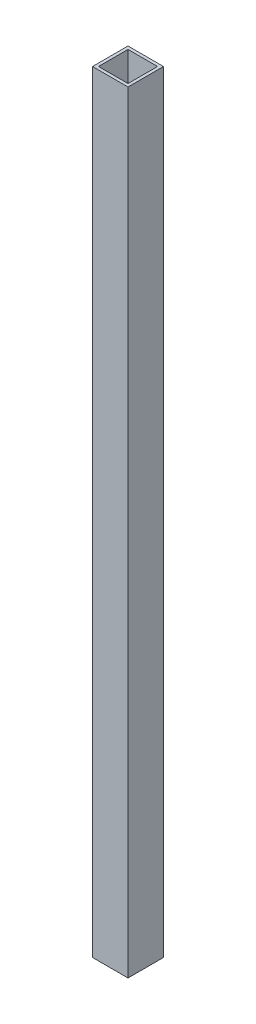
from build123d import *

# Parameters (mm, degrees)
SKETCH2_W           = 19.05
SKETCH2_H           = 19.05
SKETCH2_W_2         = 15.875
SKETCH2_H_2         = 15.875
BOSS_EXTRUDE1_DEPTH = 414.3375


with BuildPart() as part:
    # Sketch2 → Boss-Extrude1 (new body)
    with BuildSketch(Plane(origin=(0, 0, 0), x_dir=(1, 0, 0), z_dir=(0, 1, 0))):
        with Locations((9.525, 9.525)):
            Rectangle(SKETCH2_W, SKETCH2_H)
        with Locations((9.525, 9.525)):
            Rectangle(SKETCH2_W_2, SKETCH2_H_2, mode=Mode.SUBTRACT)
    extrude(amount=BOSS_EXTRUDE1_DEPTH)


solid = part.part
